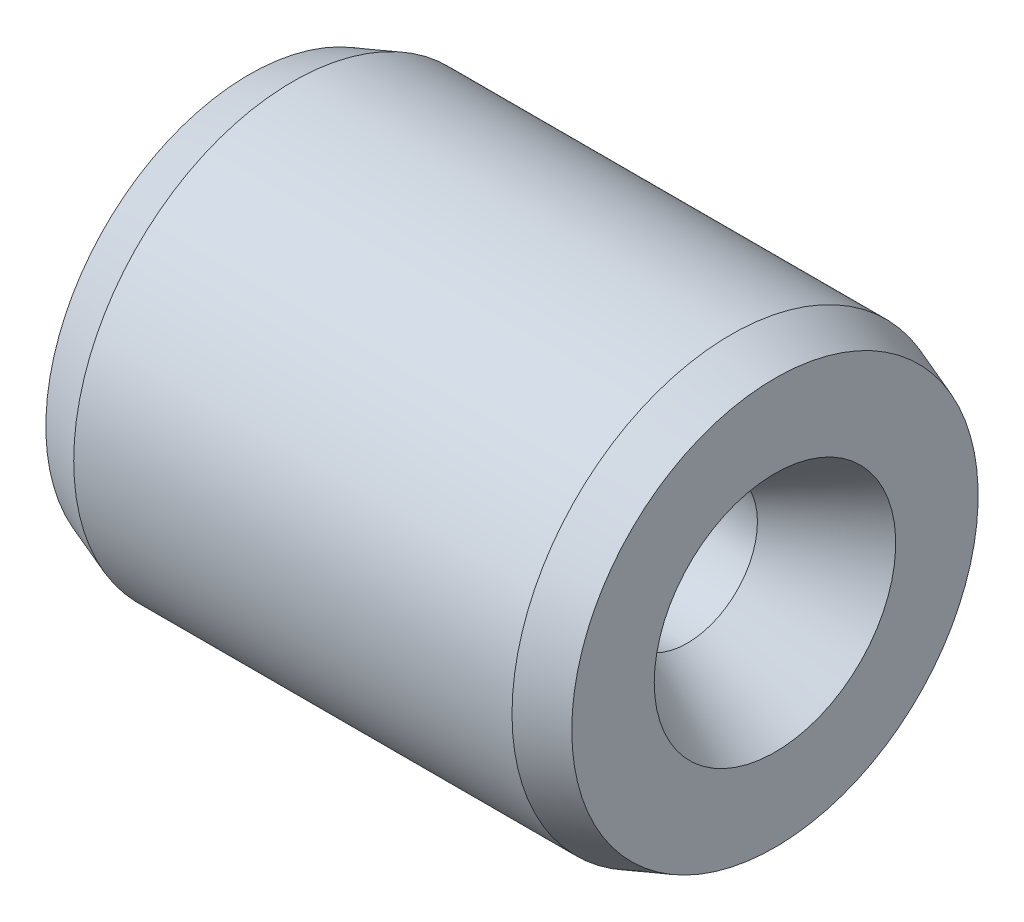
from build123d import *

# Parameters (mm, degrees)
SKIZZE1_W            = 6
SKIZZE1_H            = 2
M2_GEWINDEBOHRUNG1_D = 1.6
FASE1_SIZE           = 0.5
FASE1_SIZE2          = 0.181985117
FASE2_SIZE           = 1
FASE2_SIZE2          = 0.577350269


with BuildPart() as part:
    # Skizze1 → Rotation1 (revolve)
    with BuildSketch(Plane.XY):
        with Locations((3, 1.5)):
            Rectangle(SKIZZE1_W, SKIZZE1_H)
    revolve(axis=Axis((0, 0, 0), (1, 0, 0)))

    # M2 Gewindebohrung1 (through all)
    with Locations(Plane(origin=(6, 0, 0), x_dir=(0, 0, -1), z_dir=(1, 0, 0))):
        with Locations((0, 0)):
            Hole(M2_GEWINDEBOHRUNG1_D / 2)

    # Fase1
    fase1_edges = [part.edges().sort_by_distance(p)[0] for p in [
        (6, -2.5, 0),
        (0, -2.5, 0),
    ]]
    fase1_side = [part.faces().sort_by_distance(p)[0] for p in [
        (3, -2.5, 0),
    ]]
    chamfer(fase1_edges, length=FASE1_SIZE, length2=FASE1_SIZE2, reference=fase1_side[0])

    # Fase2
    fase2_edges = [part.edges().sort_by_distance(p)[0] for p in [
        (6, 0, -0.8),
        (0, 0, -0.8),
    ]]
    fase2_side = [part.faces().sort_by_distance(p)[0] for p in [
        (3, 0, -0.8),
    ]]
    chamfer(fase2_edges, length=FASE2_SIZE, length2=FASE2_SIZE2, reference=fase2_side[0])


solid = part.part
